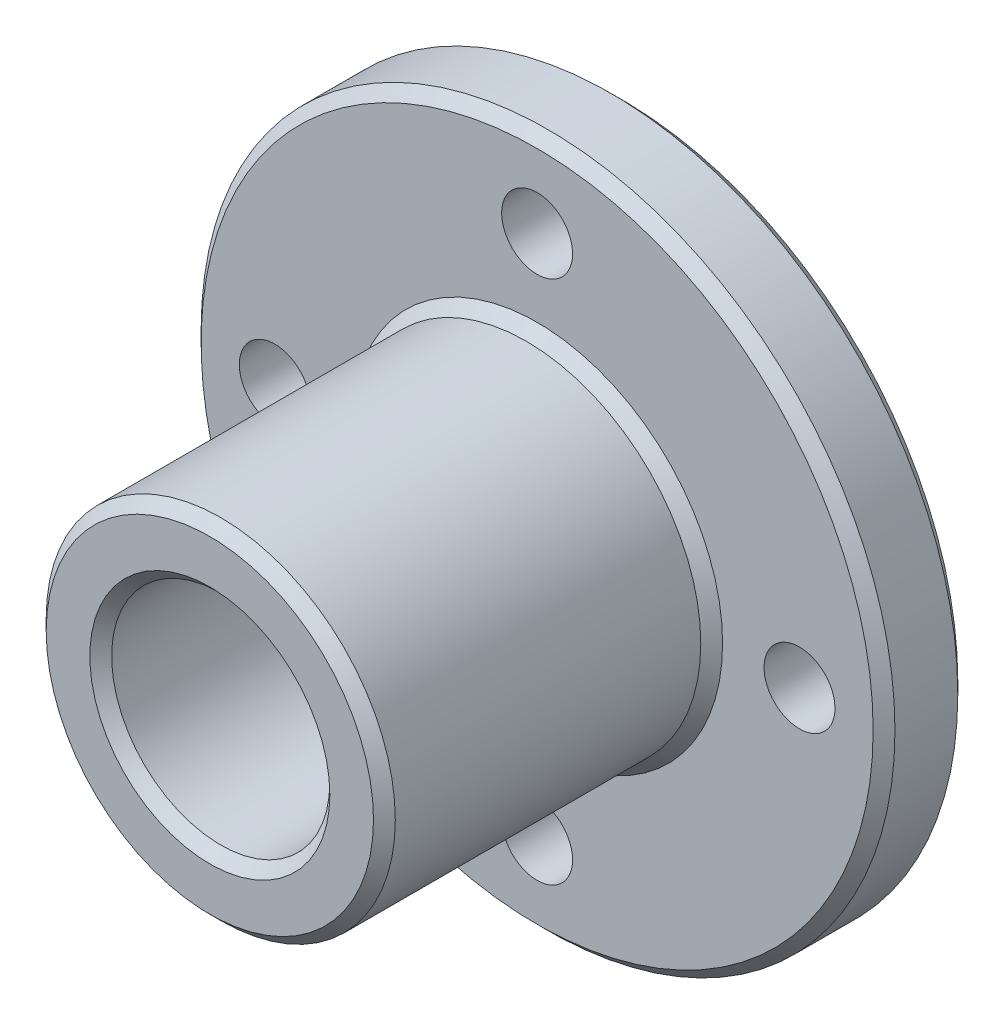
from build123d import *

# Parameters (mm, degrees)
SKETCH1_R           = 15.9
SKETCH1_R_2         = 5
SKETCH1_R_3         = 1.625
BOSS_EXTRUDE1_DEPTH = 3.88
SKETCH2_R           = 8
SKETCH2_R_2         = 5
BOSS_EXTRUDE2_DEPTH = 15
CHAMFER1_SIZE       = 0.5


with BuildPart() as part:
    # Sketch1 → Boss-Extrude1 (new body)
    with BuildSketch(Plane.XY):
        Circle(SKETCH1_R)
        Circle(SKETCH1_R_2, mode=Mode.SUBTRACT)
        with Locations((0, 12.025)):
            Circle(SKETCH1_R_3, mode=Mode.SUBTRACT)
        with Locations((12.025, 0)):
            Circle(SKETCH1_R_3, mode=Mode.SUBTRACT)
        with Locations((0, -12.025)):
            Circle(SKETCH1_R_3, mode=Mode.SUBTRACT)
        with Locations((-12.025, 0)):
            Circle(SKETCH1_R_3, mode=Mode.SUBTRACT)
    extrude(amount=BOSS_EXTRUDE1_DEPTH)

    # Sketch2 → Boss-Extrude2 (add)
    with BuildSketch(Plane.XY.offset(3.88)):
        Circle(SKETCH2_R)
        Circle(SKETCH2_R_2, mode=Mode.SUBTRACT)
    extrude(amount=BOSS_EXTRUDE2_DEPTH)

    # Chamfer1
    chamfer1_edges = [part.edges().sort_by_distance(p)[0] for p in [
        (-15.9, 0, 0),
        (-8, 0, 18.88),
        (-8, 0, 3.88),
        (-5, 0, 18.88),
        (-15.9, 0, 3.88),
    ]]
    chamfer(chamfer1_edges, length=CHAMFER1_SIZE)


solid = part.part
